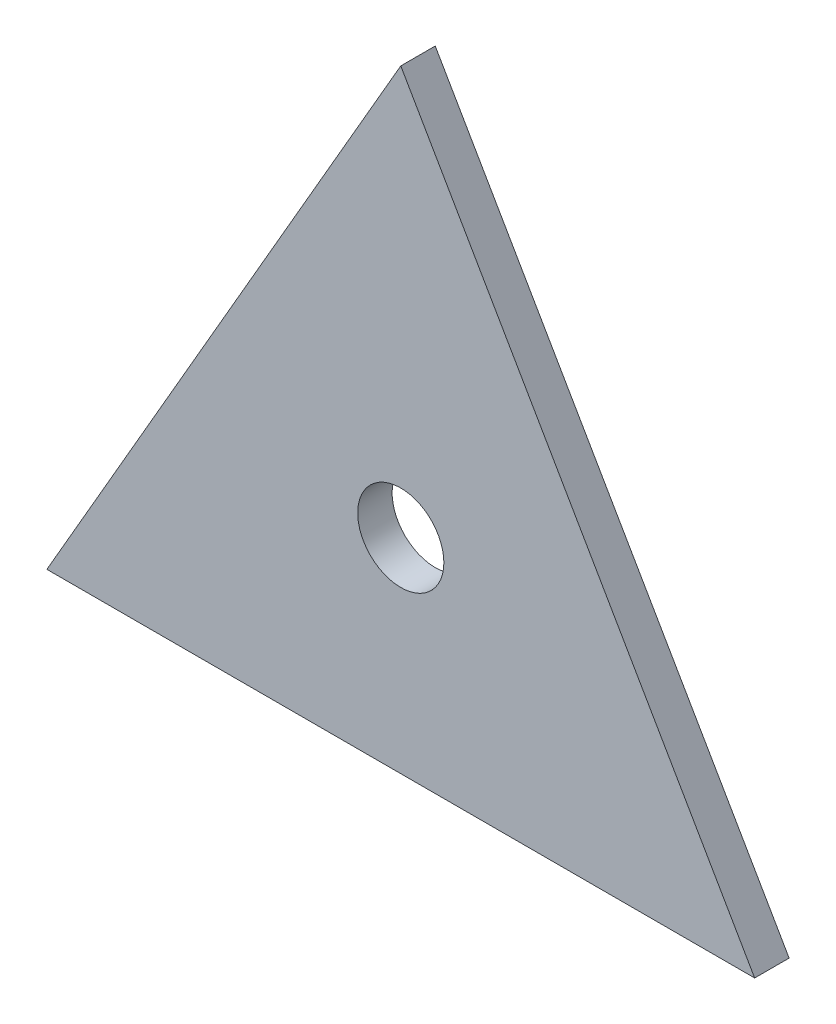
from build123d import *

# Parameters (mm, degrees)
BOSS_EXTRUDE1_DEPTH = 12.7
SKETCH2_R           = 15.875
CUT_EXTRUDE2_DEPTH  = 38.1


with BuildPart() as part:
    # Sketch1 → Boss-Extrude1 (new body)
    with BuildSketch(Plane.XY):
        Polygon((-282.802954744, 12.7), (-21.997045256, 12.7), (-152.4, 238.564543073), align=None)
    extrude(amount=-BOSS_EXTRUDE1_DEPTH)

    # Sketch2 → Cut-Extrude2 (cut)
    with BuildSketch(Plane.XY):
        with Locations((-152.4, 87.988181024)):
            Circle(SKETCH2_R)
    extrude(amount=-CUT_EXTRUDE2_DEPTH, mode=Mode.SUBTRACT)


solid = part.part
